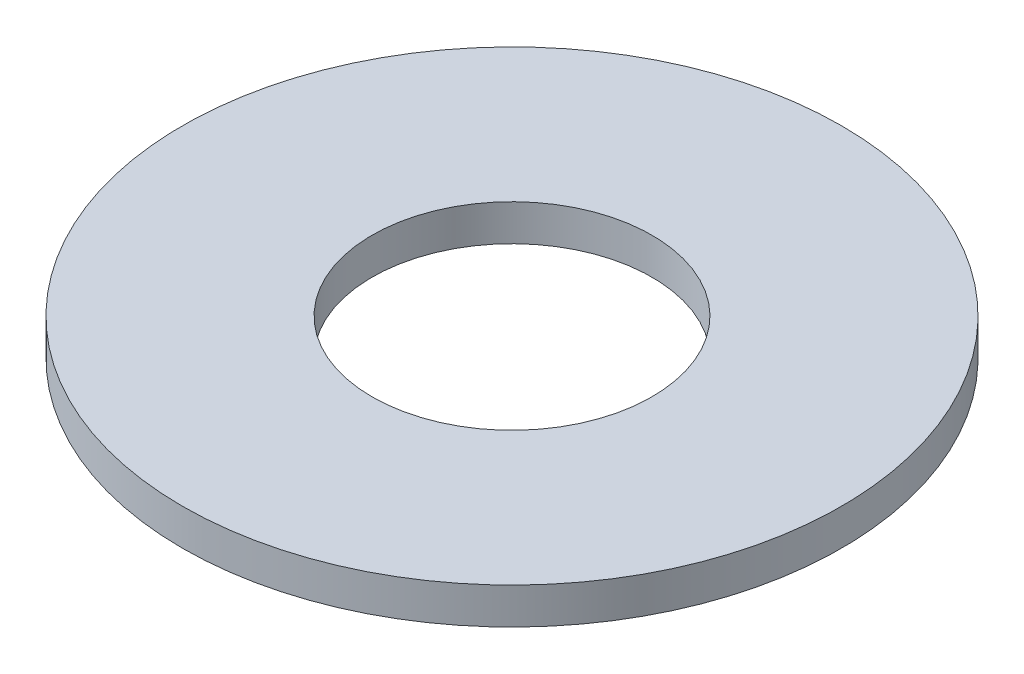
from build123d import *

# Parameters (mm, degrees)
SKETCH1_R           = 15.875
BOSS_EXTRUDE1_DEPTH = 1.7526
SKETCH5_R           = 6.7437
CUT_EXTRUDE1_DEPTH  = 2.7526


with BuildPart() as part:
    # Sketch1 → Boss-Extrude1 (new body)
    with BuildSketch(Plane(origin=(0, 0, 0), x_dir=(1, 0, 0), z_dir=(0, 1, 0))):
        Circle(SKETCH1_R)
    extrude(amount=BOSS_EXTRUDE1_DEPTH)

    # Sketch5 → Cut-Extrude1 (cut, through all)
    with BuildSketch(Plane(origin=(0, 1.7526, 0), x_dir=(-1, 0, 0), z_dir=(0, 1, 0))):
        Circle(SKETCH5_R)
    extrude(amount=-CUT_EXTRUDE1_DEPTH, mode=Mode.SUBTRACT)


solid = part.part
